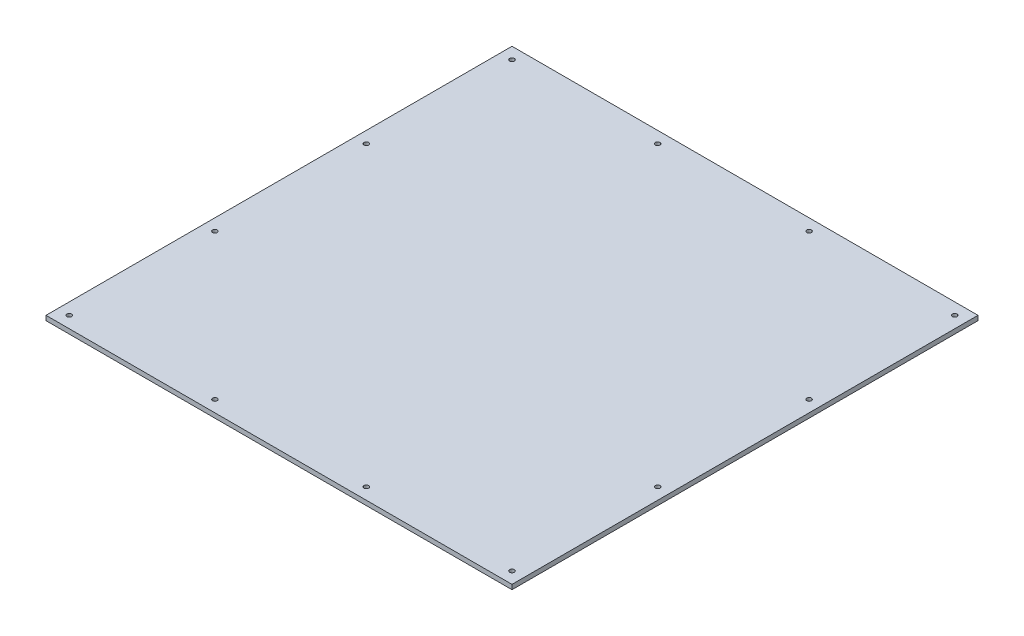
from build123d import *

# Parameters (mm, degrees)
SKETCH1_W           = 400
SKETCH1_H           = 400
SKETCH1_R           = 2
BOSS_EXTRUDE1_DEPTH = 4


with BuildPart() as part:
    # Sketch1 → Boss-Extrude1 (new body)
    with BuildSketch(Plane(origin=(0, 0, 0), x_dir=(1, 0, 0), z_dir=(0, 1, 0))):
        Rectangle(SKETCH1_W, SKETCH1_H)
        with Locations((-190, -190)):
            Circle(SKETCH1_R, mode=Mode.SUBTRACT)
        with Locations((-65, -190)):
            Circle(SKETCH1_R, mode=Mode.SUBTRACT)
        with Locations((65, -190)):
            Circle(SKETCH1_R, mode=Mode.SUBTRACT)
        with Locations((190, -190)):
            Circle(SKETCH1_R, mode=Mode.SUBTRACT)
        with Locations((-190, 190)):
            Circle(SKETCH1_R, mode=Mode.SUBTRACT)
        with Locations((-190, 65)):
            Circle(SKETCH1_R, mode=Mode.SUBTRACT)
        with Locations((-190, -65)):
            Circle(SKETCH1_R, mode=Mode.SUBTRACT)
        with Locations((190, 190)):
            Circle(SKETCH1_R, mode=Mode.SUBTRACT)
        with Locations((65, 190)):
            Circle(SKETCH1_R, mode=Mode.SUBTRACT)
        with Locations((-65, 190)):
            Circle(SKETCH1_R, mode=Mode.SUBTRACT)
        with Locations((190, 65)):
            Circle(SKETCH1_R, mode=Mode.SUBTRACT)
        with Locations((190, -65)):
            Circle(SKETCH1_R, mode=Mode.SUBTRACT)
    extrude(amount=BOSS_EXTRUDE1_DEPTH)


solid = part.part
